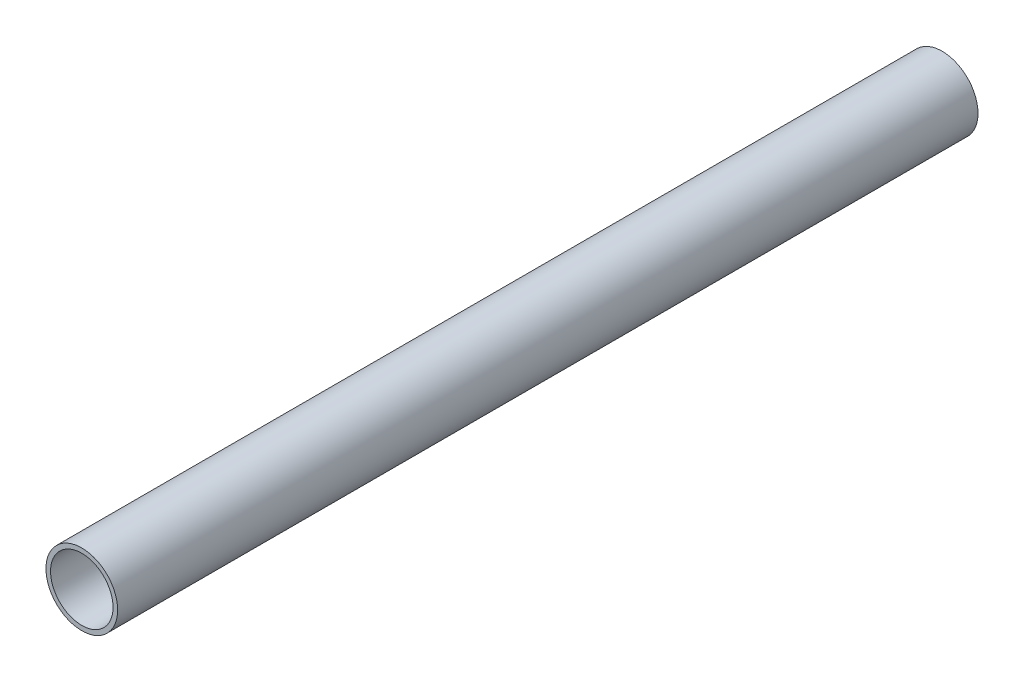
from build123d import *

# Parameters (mm, degrees)
SKETCH2_R           = 6.35
SKETCH2_R_2         = 5.5372
BOSS_EXTRUDE1_DEPTH = 76.2


with BuildPart() as part:
    # Sketch2 → Boss-Extrude1 (new, symmetric)
    with BuildSketch(Plane.XY):
        Circle(SKETCH2_R)
        Circle(SKETCH2_R_2, mode=Mode.SUBTRACT)
    extrude(amount=BOSS_EXTRUDE1_DEPTH, both=True)


solid = part.part
